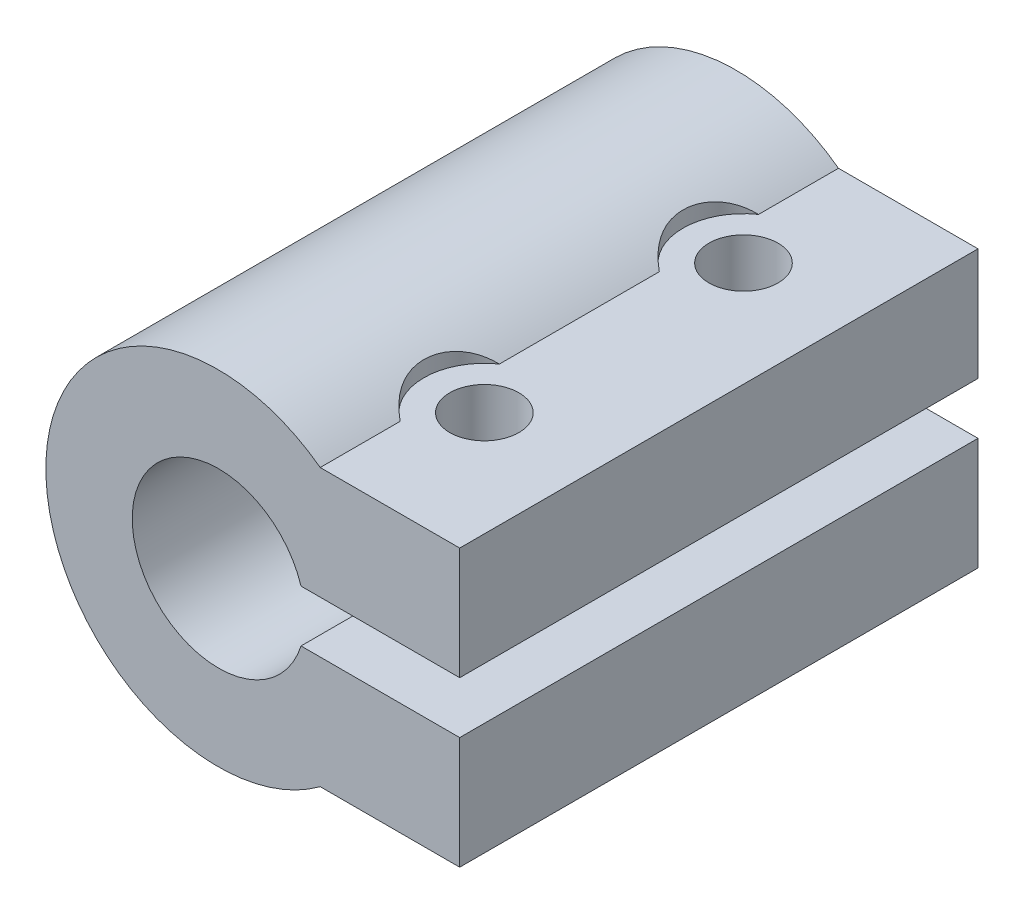
from build123d import *

# Parameters (mm, degrees)
SKETCH1_W               = 30
SKETCH1_H               = 16
BOSS_EXTRUDE1_DEPTH     = 14
SKETCH3_R               = 9.955
BOSS_EXTRUDE2_DEPTH     = 30
SKETCH4_W               = 11.4
SKETCH4_H               = 3
CUT_EXTRUDE1_DEPTH      = 30
SKETCH5_R               = 5
CUT_EXTRUDE2_DEPTH      = 15
CUT_EXTRUDE5_DEPTH      = 15
CUT_EXTRUDE7_DEPTH      = 1
CUT_EXTRUDE7_DEPTH_BACK = 3
SKETCH7_R               = 2
SKETCH7_W               = 7.475303805
SKETCH7_H               = 1
SKETCH7_4_R             = 2
CUT_EXTRUDE9_DEPTH      = 34.910470056
SKETCH11_R              = 3.5
CUT_EXTRUDE10_DEPTH     = 0.93


with BuildPart() as part:
    # Sketch1 → Boss-Extrude1 (new body)
    with BuildSketch(Plane(origin=(0, 0, 0), x_dir=(0, 0, -1), z_dir=(1, 0, 0))):
        with Locations((0.927835052, 0.737113402)):
            Rectangle(SKETCH1_W, SKETCH1_H)
    extrude(amount=-BOSS_EXTRUDE1_DEPTH)

    # Sketch3 → Boss-Extrude2 (add)
    with BuildSketch(Plane(origin=(0, 0, -15.927835052), x_dir=(-1, 0, 0), z_dir=(0, 0, -1))):
        with Locations((14, 0.737113402)):
            Circle(SKETCH3_R)
    extrude(amount=-BOSS_EXTRUDE2_DEPTH)

    # Sketch4 → Cut-Extrude1 (cut)
    with BuildSketch(Plane(origin=(0, 0, -15.927835052), x_dir=(-1, 0, 0), z_dir=(0, 0, -1))):
        with Locations((5.7, 0.737113402)):
            Rectangle(SKETCH4_W, SKETCH4_H)
    extrude(amount=-CUT_EXTRUDE1_DEPTH, mode=Mode.SUBTRACT)

    # Sketch5 → Cut-Extrude2 (cut)
    with BuildSketch(Plane.XY.offset(14.072164948)):
        with Locations((-13.955, 0.737113402)):
            Circle(SKETCH5_R)
    extrude(amount=-CUT_EXTRUDE2_DEPTH, mode=Mode.SUBTRACT)

    # Sketch6 → Cut-Extrude5 (cut)
    with BuildSketch(Plane(origin=(0, 0, -15.927835052), x_dir=(-1, 0, 0), z_dir=(0, 0, -1))):
        with BuildLine():
            Line((16, 2.987113402), (16, -1.512886598))
            ThreePointArc((16, -1.512886598), (11.015686517, 0.737113402), (16, 2.987113402))
        make_face()
    extrude(amount=-CUT_EXTRUDE5_DEPTH, mode=Mode.SUBTRACT)

    # Sketch7 → Cut-Extrude7 (cut, two sides: drawn at the far end of the back side and taken through both)
    # profile 1 of 3: a face of its own
    with BuildSketch(Plane.XZ.offset(7.262886598).offset(-CUT_EXTRUDE7_DEPTH_BACK)):
        Polygon((-6.074118703, 3.222164948), (-3.1729336, 4.897164948), (-3.1729336, 8.247164948), (-6.074118703, 9.922164948), (-8.975303805, 8.247164948), (-8.975303805, 4.897164948), align=None)
        with Locations((-6.074118703, 6.572164948)):
            Circle(SKETCH7_R, mode=Mode.SUBTRACT)
    # profile 2 of 3: a face of its own
    with BuildSketch(Plane.XZ.offset(7.262886598).offset(-CUT_EXTRUDE7_DEPTH_BACK)):
        Polygon((-6.074118703, -5.077835052), (-8.975303805, -6.752835052), (-8.975303805, -10.102835052), (-6.074118703, -11.777835052), (-3.1729336, -10.102835052), (-3.1729336, -6.752835052), align=None)
    # profile 3 of 3: a face of its own
    with BuildSketch(Plane.XZ.offset(7.262886598).offset(-CUT_EXTRUDE7_DEPTH_BACK)):
        with Locations((-5.237651903, -0.927835052)):
            Rectangle(SKETCH7_W, SKETCH7_H)
    extrude(amount=CUT_EXTRUDE7_DEPTH + CUT_EXTRUDE7_DEPTH_BACK, mode=Mode.SUBTRACT)

    # Sketch7_4 → Cut-Extrude9 (cut, through all)
    with BuildSketch(Plane.XZ.offset(7.262886598)):
        with Locations((-6.074118703, -8.427835052)):
            Circle(SKETCH7_4_R)
        with Locations((-6.074118703, 6.572164948)):
            Circle(SKETCH7_4_R)
    extrude(amount=-CUT_EXTRUDE9_DEPTH, mode=Mode.SUBTRACT)

    # Sketch11 → Cut-Extrude10 (cut)
    with BuildSketch(Plane(origin=(0, 8.737113402, 0), x_dir=(1, 0, 0), z_dir=(0, 1, 0))):
        with Locations((-6.074118703, -6.572164948)):
            Circle(SKETCH11_R)
        with Locations((-6.074118703, 8.427835052)):
            Circle(SKETCH11_R)
    extrude(amount=CUT_EXTRUDE10_DEPTH, mode=Mode.SUBTRACT)


solid = part.part
